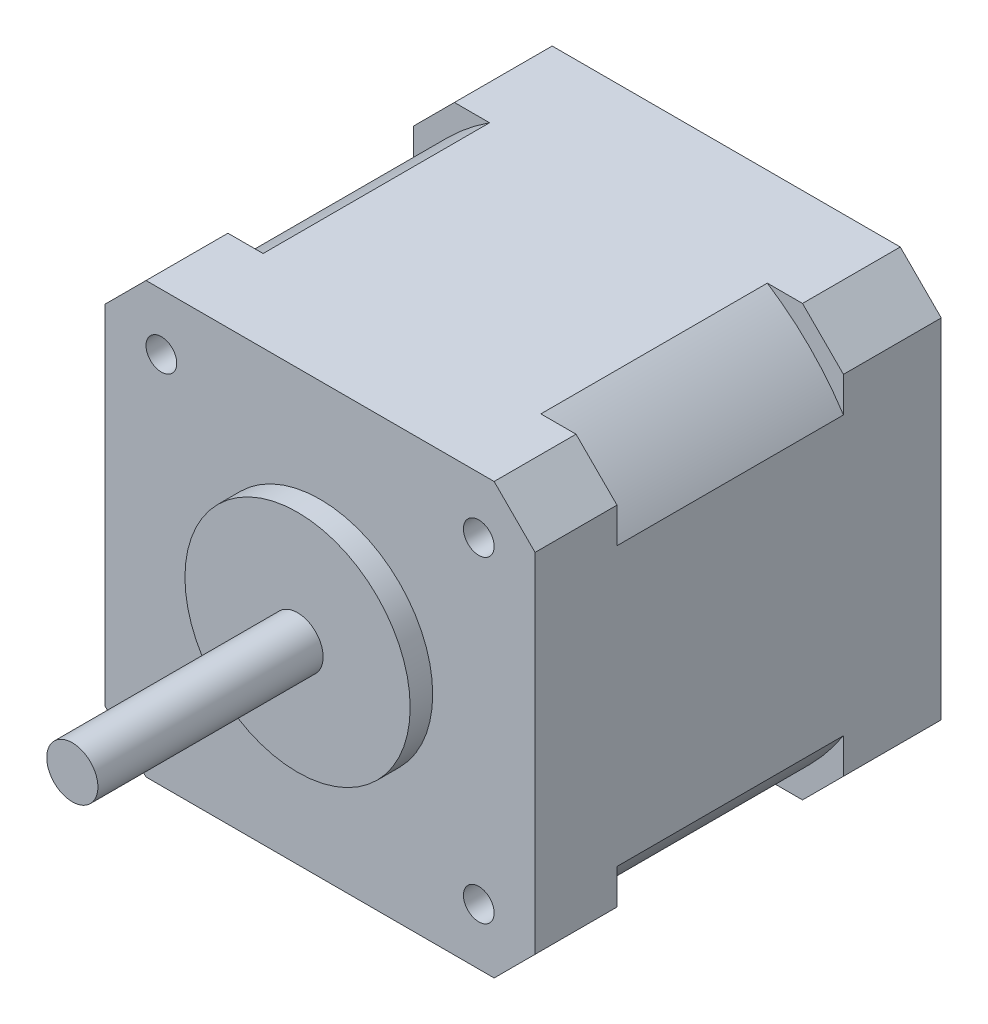
from build123d import *

# Parameters (mm, degrees)
BOSS_EXTRUDE1_DEPTH = 39.67
SKETCH2_OUTSIDE_W   = 58.286
SKETCH2_OUTSIDE_H   = 58.286
SKETCH2_OUTSIDE_R   = 25
CUT_EXTRUDE1_DEPTH  = 22.12
SKETCH3_R           = 1.5
CUT_EXTRUDE2_DEPTH  = 5
SKETCH4_R           = 4.75
CUT_EXTRUDE3_DEPTH  = 2
SKETCH5_R           = 1.5
CUT_EXTRUDE4_DEPTH  = 5
SKETCH6_R           = 11
BOSS_EXTRUDE2_DEPTH = 2.2
SKETCH8_R           = 2.5
BOSS_EXTRUDE3_DEPTH = 22


with BuildPart() as part:
    # Sketch1 → Boss-Extrude1 (new body)
    with BuildSketch(Plane.XY):
        Polygon((17, -21), (21, -17), (21, 17), (17, 21), (-17, 21), (-21, 17), (-21, -17), (-17, -21), align=None)
    extrude(amount=-BOSS_EXTRUDE1_DEPTH)

    # Sketch2 outside → Cut-Extrude1 (cut)
    with BuildSketch(Plane.XY.offset(-30.12)):
        Rectangle(SKETCH2_OUTSIDE_W, SKETCH2_OUTSIDE_H)
        Circle(SKETCH2_OUTSIDE_R, mode=Mode.SUBTRACT)
    extrude(amount=CUT_EXTRUDE1_DEPTH, mode=Mode.SUBTRACT)

    # Sketch3 → Cut-Extrude2 (cut)
    with BuildSketch(Plane(origin=(0, 0, -39.67), x_dir=(-1, 0, 0), z_dir=(0, 0, -1))):
        with Locations((15.5, 15.5)):
            Circle(SKETCH3_R)
        with Locations((15.5, -15.5)):
            Circle(SKETCH3_R)
        with Locations((-15.5, -15.5)):
            Circle(SKETCH3_R)
        with Locations((-15.5, 15.5)):
            Circle(SKETCH3_R)
    extrude(amount=-CUT_EXTRUDE2_DEPTH, mode=Mode.SUBTRACT)

    # Sketch4 → Cut-Extrude3 (cut)
    with BuildSketch(Plane(origin=(0, 0, -39.67), x_dir=(-1, 0, 0), z_dir=(0, 0, -1))):
        Circle(SKETCH4_R)
    extrude(amount=-CUT_EXTRUDE3_DEPTH, mode=Mode.SUBTRACT)

    # Sketch5 → Cut-Extrude4 (cut)
    with BuildSketch(Plane.XY):
        with Locations((15.5, 15.5)):
            Circle(SKETCH5_R)
        with Locations((-15.5, 15.5)):
            Circle(SKETCH5_R)
        with Locations((-15.5, -15.5)):
            Circle(SKETCH5_R)
        with Locations((15.5, -15.5)):
            Circle(SKETCH5_R)
    extrude(amount=-CUT_EXTRUDE4_DEPTH, mode=Mode.SUBTRACT)


with BuildPart() as body_2:
    # Sketch6 → Boss-Extrude2 (new body)
    with BuildSketch(Plane.XY):
        Circle(SKETCH6_R)
    extrude(amount=BOSS_EXTRUDE2_DEPTH)

    # Sketch8 → Boss-Extrude3 (add)
    with BuildSketch(Plane.XY.offset(2.2)):
        Circle(SKETCH8_R)
    extrude(amount=BOSS_EXTRUDE3_DEPTH)


solid = Compound([part.part, body_2.part])
